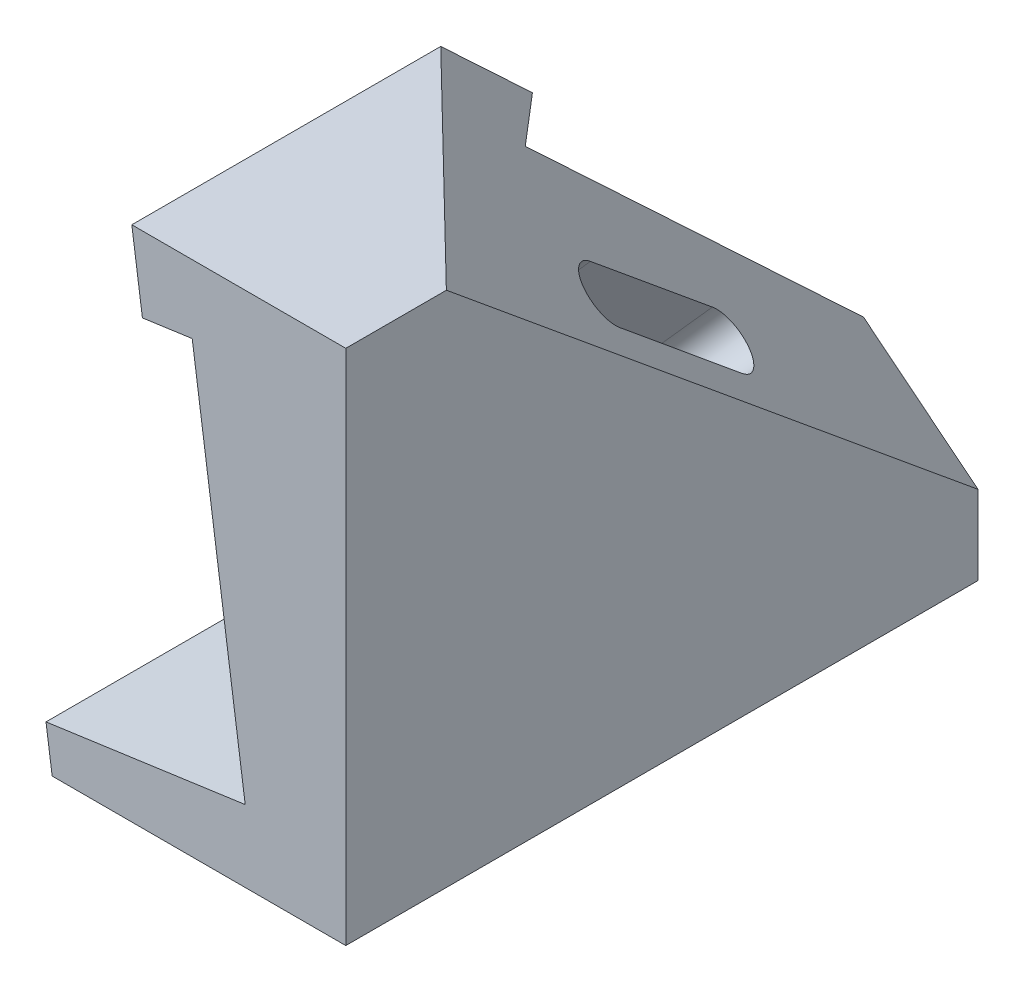
from build123d import *

# Parameters (mm, degrees)
BOSS_EXTRUDE1_DEPTH = 88
SKETCH5_W           = 120.314234724
SKETCH5_H           = 205.924557391
CUT_EXTRUDE1_DEPTH  = 88
CUT_EXTRUDE2_REACH  = 78.774


with BuildPart() as part:
    # Sketch2 → Boss-Extrude1 (new body)
    with BuildSketch(Plane.XY):
        Polygon((21.738330866, 28.073521819), (21.738330866, -43.926478181), (-19.131432817, -43.926478181), (-19.989175059, -37.823325008), (7.738330866, -33.926478181), (0.362156515, 18.557729462), (-6.569719966, 17.583517755), (-8.043993893, 28.073521819), align=None)
    extrude(amount=-BOSS_EXTRUDE1_DEPTH)

    # Sketch5 → Cut-Extrude1 (cut)
    with BuildSketch(Plane(origin=(19.710307893, 24.555901932, -20.242027268), x_dir=(-0.850144649, 0.406300724, -0.33492357), z_dir=(-0.526549216, -0.655996394, 0.540753784))):
        with Locations((18.13624664, 41.178747918)):
            Rectangle(SKETCH5_W, SKETCH5_H)
    extrude(amount=-CUT_EXTRUDE1_DEPTH, mode=Mode.SUBTRACT)

    # Cut-Extrude2: up to this face of the body (flat: up to its plane)
    cut_extrude2_end = Plane(part.part.faces().sort_by_distance((4.446485826, -10.503783654, -37.636714234))[0])
    # Sketch6 → Cut-Extrude2 (cut, up to the picked face)
    with BuildSketch(Plane(origin=(19.710307893, 24.555901932, -20.242027268), x_dir=(0.850144649, -0.406300724, 0.33492357), z_dir=(0.526549216, 0.655996394, -0.540753784)), mode=Mode.PRIVATE) as cut_extrude2_sk1:
        with BuildLine():
            Line((-1.614496573, 26.946007892), (-1.614496573, 48.946007892))
            ThreePointArc((-1.614496573, 48.946007892), (-5.614496573, 52.946007892), (-9.614496573, 48.946007892))
            Line((-9.614496573, 48.946007892), (-9.614496573, 26.946007892))
            ThreePointArc((-9.614496573, 26.946007892), (-5.614496573, 22.946007892), (-1.614496573, 26.946007892))
        make_face()
    cut_extrude2_tool1 = split(extrude(cut_extrude2_sk1.sketch, amount=-CUT_EXTRUDE2_REACH, mode=Mode.PRIVATE), bisect_by=cut_extrude2_end, keep=Keep.BOTH, mode=Mode.PRIVATE)
    add(cut_extrude2_tool1.solids().sort_by_distance((14.937174, 2.700657, -51.4027))[0], mode=Mode.SUBTRACT)


solid = part.part
